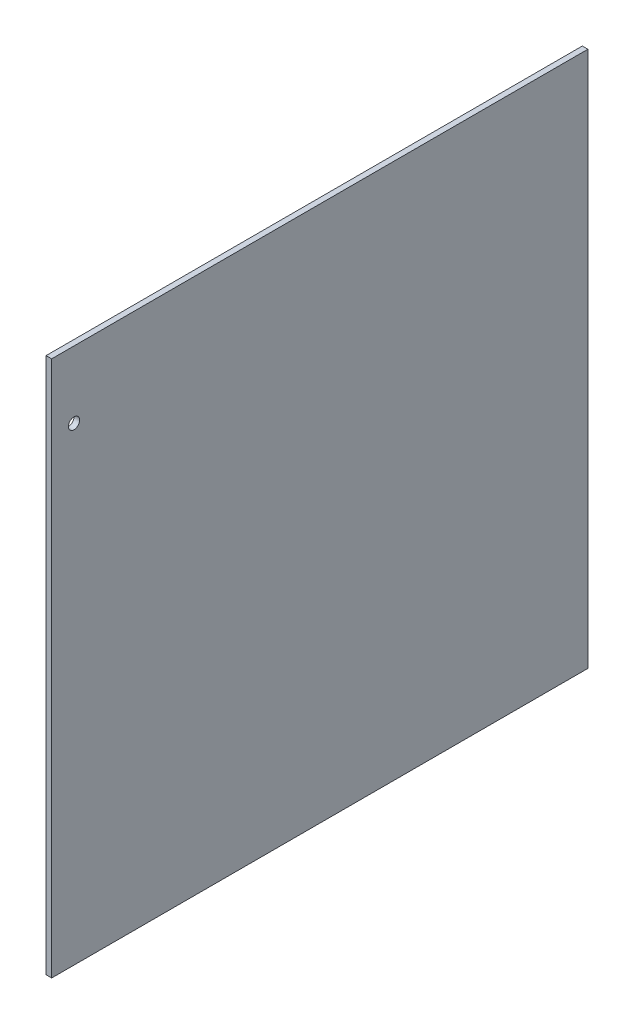
from build123d import *

# Parameters (mm, degrees)
SKETCH1_W           = 304.8
SKETCH1_H           = 304.8
BOSS_EXTRUDE1_DEPTH = 3.175
SKETCH2_R           = 3.175
CUT_EXTRUDE1_DEPTH  = 4.175


with BuildPart() as part:
    # Sketch1 → Boss-Extrude1 (new body)
    with BuildSketch(Plane(origin=(0, 0, 0), x_dir=(0, 0, -1), z_dir=(1, 0, 0))):
        Rectangle(SKETCH1_W, SKETCH1_H)
    extrude(amount=BOSS_EXTRUDE1_DEPTH)

    # Sketch2 → Cut-Extrude1 (cut, through all)
    with BuildSketch(Plane.ZY):
        with Locations((139.7, 114.3)):
            Circle(SKETCH2_R)
    extrude(amount=-CUT_EXTRUDE1_DEPTH, mode=Mode.SUBTRACT)


solid = part.part
